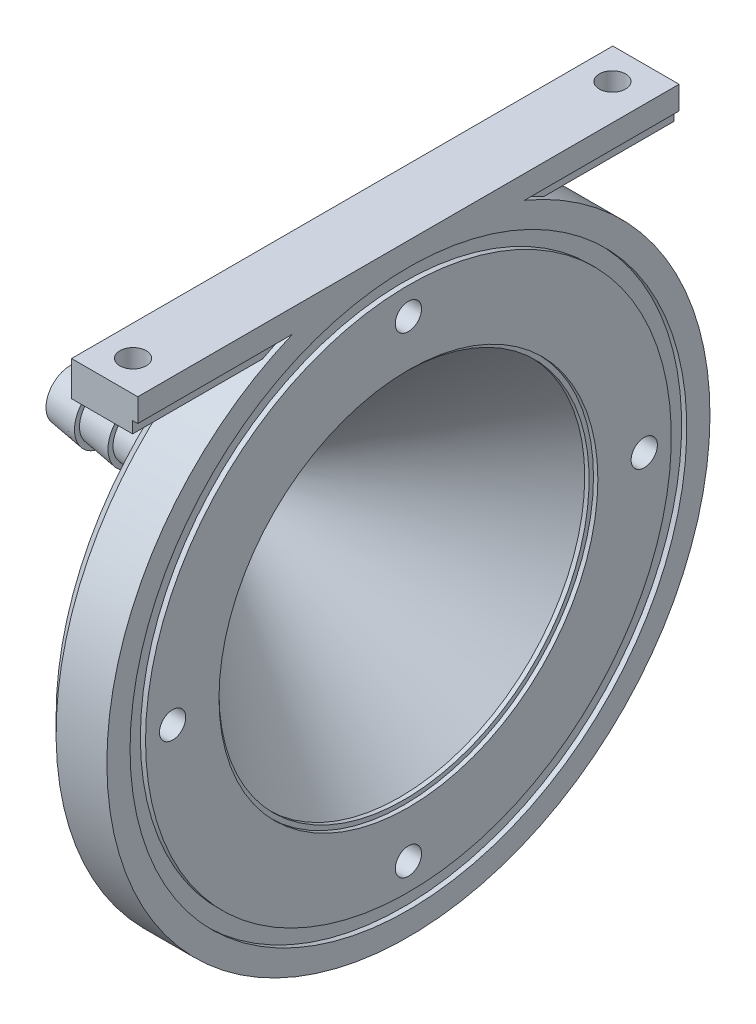
from build123d import *

# Parameters (mm, degrees)
M3_CLEARANCE_HOLE1_D     = 3.4
M3_CLEARANCE_HOLE1_DEPTH = 8.566
M3_CLEARANCE_HOLE1_TIP   = 1.021463052
CHAMFER1_SIZE            = 2
BOSS_EXTRUDE1_DEPTH      = 35
SKETCH9_R                = 1.7
CUT_EXTRUDE1_DEPTH       = 10


with BuildPart() as part:
    # Sketch1 → Revolve17 (revolve)
    with BuildSketch(Plane.XY):
        Polygon((-14.010170791, 3.15), (-14.010170791, 3.8), (-18.343504124, 3.15), (-18.343504124, 1.9), (0, 1.9), (24.243150592, 23.934), (24.809150592, 23.934), (24.809150592, 24.5), (25.375150592, 24.5), (25.375150592, 34), (24.708150592, 34), (24.708150592, 36), (25.375150592, 36), (25.375150592, 39), (16.809150592, 39), (16.809150592, 23.934), (-5.343504124, 3.8), (-9.676837458, 3.15), (-9.676837458, 3.8), align=None)
    revolve(axis=Axis((-801.927103621, 0, 0), (1, 0, 0)))

    # M3 Clearance Hole1
    with Locations(Plane.ZY.offset(-16.809150592)):
        with Locations((0, -30.5), (0, 30.5), (30.5, 0), (-30.5, 0)):
            Hole(M3_CLEARANCE_HOLE1_D / 2, depth=M3_CLEARANCE_HOLE1_DEPTH)
            with Locations((0, 0, -(M3_CLEARANCE_HOLE1_DEPTH + M3_CLEARANCE_HOLE1_TIP / 2))):  # 118° drill point
                Cone(0, M3_CLEARANCE_HOLE1_D / 2, M3_CLEARANCE_HOLE1_TIP, mode=Mode.SUBTRACT)

    # Chamfer1
    chamfer1_edges = [part.edges().sort_by_distance(p)[0] for p in [
        (16.809150592, -39, 0),
    ]]
    chamfer(chamfer1_edges, length=CHAMFER1_SIZE)

    # Sketch1_11 → Boss-Extrude1 (add, symmetric)
    with BuildSketch(Plane.XY):
        Polygon((16.809150592, 39), (16.809150592, 34.5), (24.708150592, 34.5), (24.708150592, 36), (25.375150592, 36), (25.375150592, 39), align=None)
    extrude(amount=BOSS_EXTRUDE1_DEPTH, both=True)

    # Sketch9 → Cut-Extrude1 (cut)
    with BuildSketch(Plane(origin=(0, 34.5, 0), x_dir=(-1, 0, 0), z_dir=(0, -1, 0))):
        with Locations((-20.758650592, -31)):
            Circle(SKETCH9_R)
        with Locations((-20.758650592, 31)):
            Circle(SKETCH9_R)
    extrude(amount=-CUT_EXTRUDE1_DEPTH, mode=Mode.SUBTRACT)


solid = part.part
